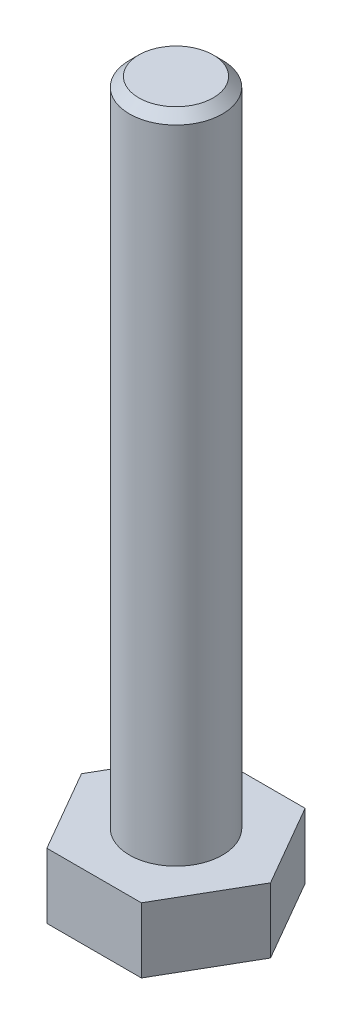
from build123d import *

# Parameters (mm, degrees)
SKETCH1_R           = 2.5
BOSS_EXTRUDE1_DEPTH = 3.5
BOSS_EXTRUDE2_START = 3.5
SKETCH1_3_R         = 2.5
BOSS_EXTRUDE2_DEPTH = 35
CHAMFER1_SIZE       = 0.5


with BuildPart() as part:
    # Sketch1 → Boss-Extrude1 (new body)
    with BuildSketch(Plane(origin=(0, 0, 0), x_dir=(1, 0, 0), z_dir=(0, 1, 0))):
        Polygon((-5.080682369, 0), (-2.540341184, -4.4), (2.540341184, -4.4), (5.080682369, 0), (2.540341184, 4.4), (-2.540341184, 4.4), align=None)
        Circle(SKETCH1_R, mode=Mode.SUBTRACT)
        Circle(SKETCH1_R)
    extrude(amount=BOSS_EXTRUDE1_DEPTH)

    # Sketch1_3 → Boss-Extrude2 (add)
    with BuildSketch(Plane(origin=(0, 0, 0), x_dir=(1, 0, 0), z_dir=(0, 1, 0)).offset(BOSS_EXTRUDE2_START)):
        with Locations(Location((0, 0, 0), (0, 0, 270))):
            Circle(SKETCH1_3_R)
    extrude(amount=BOSS_EXTRUDE2_DEPTH)

    # Chamfer1
    chamfer1_edges = [part.edges().sort_by_distance(p)[0] for p in [
        (0, 38.5, -2.5),
    ]]
    chamfer(chamfer1_edges, length=CHAMFER1_SIZE)


solid = part.part
